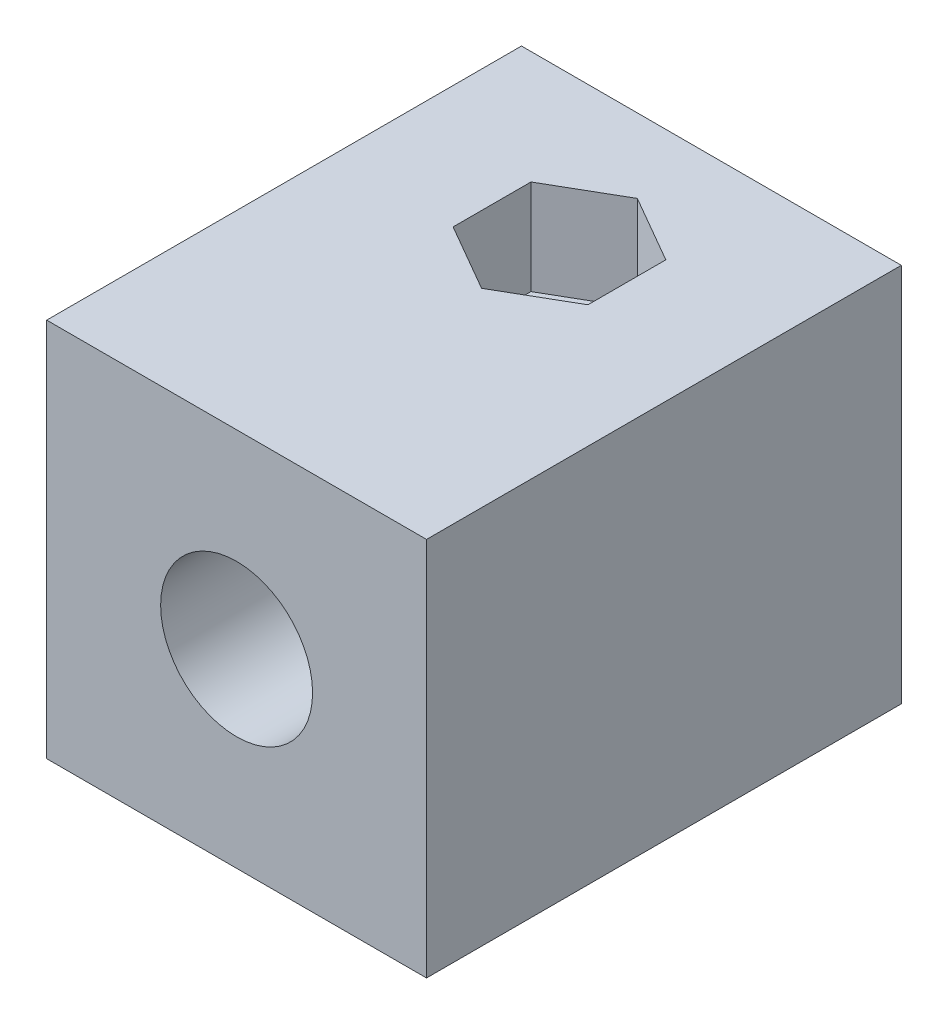
from build123d import *

# Parameters (mm, degrees)
SKETCH1_W           = 20
SKETCH1_H           = 25
BOSS_EXTRUDE1_DEPTH = 20
SKETCH2_R           = 4
CUT_EXTRUDE1_DEPTH  = 20
SKETCH3_R           = 1.5
CUT_EXTRUDE2_DEPTH  = 21
CUT_EXTRUDE3_DEPTH  = 5


with BuildPart() as part:
    # Sketch1 → Boss-Extrude1 (new body)
    with BuildSketch(Plane(origin=(0, 0, 0), x_dir=(1, 0, 0), z_dir=(0, 1, 0))):
        Rectangle(SKETCH1_W, SKETCH1_H)
    extrude(amount=BOSS_EXTRUDE1_DEPTH)

    # Sketch2 → Cut-Extrude1 (cut)
    with BuildSketch(Plane.XY.offset(12.5)):
        with Locations((0, 10)):
            Circle(SKETCH2_R)
    extrude(amount=-CUT_EXTRUDE1_DEPTH, mode=Mode.SUBTRACT)

    # Sketch3 → Cut-Extrude2 (cut, through all)
    with BuildSketch(Plane(origin=(0, 20, 0), x_dir=(1, 0, 0), z_dir=(0, 1, 0))):
        with Locations((0, 4.5)):
            Circle(SKETCH3_R)
    extrude(amount=-CUT_EXTRUDE2_DEPTH, mode=Mode.SUBTRACT)

    # Sketch4 → Cut-Extrude3 (cut)
    with BuildSketch(Plane(origin=(0, 20, 0), x_dir=(1, 0, 0), z_dir=(0, 1, 0))):
        Polygon((0, 8.6), (-3.550704156, 6.55), (-3.550704156, 2.45), (0, 0.4), (3.550704156, 2.45), (3.550704156, 6.55), align=None)
    extrude(amount=-CUT_EXTRUDE3_DEPTH, mode=Mode.SUBTRACT)


solid = part.part
